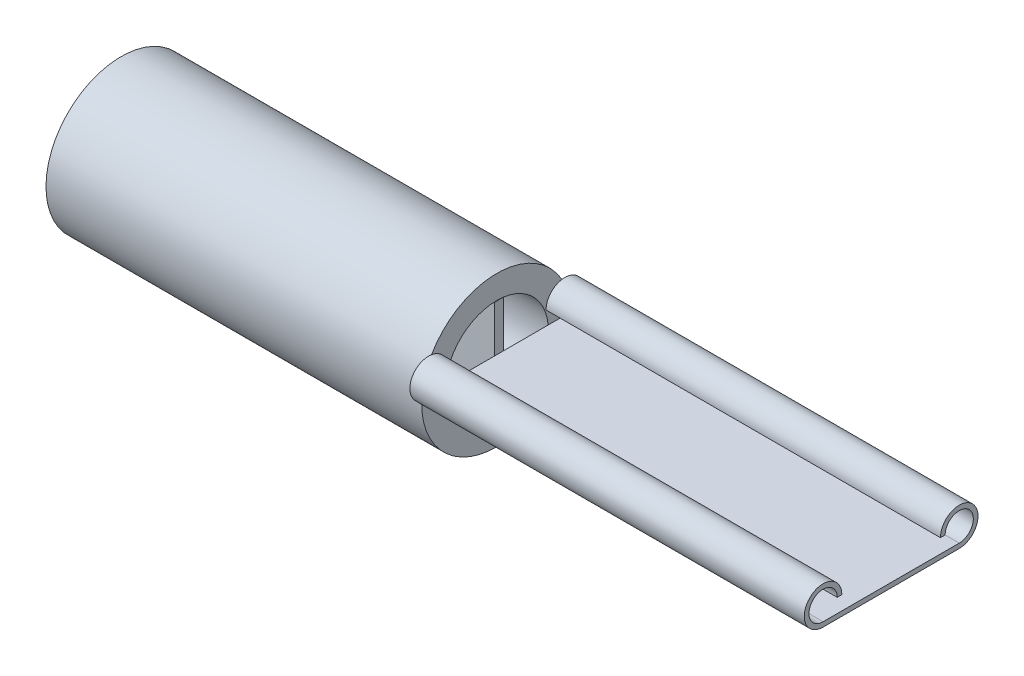
from build123d import *

# Parameters (mm, degrees)
SKETCH1_R           = 1.6
SKETCH1_R_2         = 1.1
BOSS_EXTRUDE1_DEPTH = 8
BOSS_EXTRUDE2_DEPTH = 8.4
SKETCH3_W           = 0.2
SKETCH3_H           = 2.18868951
BOSS_EXTRUDE5_DEPTH = 8


with BuildPart() as part:
    # Sketch1 → Boss-Extrude1 (new body)
    with BuildSketch(Plane(origin=(0, 0, 0), x_dir=(0, 0, -1), z_dir=(1, 0, 0))):
        Circle(SKETCH1_R)
        Circle(SKETCH1_R_2, mode=Mode.SUBTRACT)
    extrude(amount=BOSS_EXTRUDE1_DEPTH)

    # Sketch2 → Boss-Extrude2 (add)
    with BuildSketch(Plane(origin=(8, 0, 0), x_dir=(0, 0, -1), z_dir=(1, 0, 0))):
        with BuildLine():
            Line((-1.45, 0), (1.45, 0))
            ThreePointArc((1.45, 0), (1.732842712, 0.682842712), (1.05, 0.4))
            Line((1.05, 0.4), (1.15, 0.4))
            ThreePointArc((1.15, 0.4), (1.662132034, 0.612132034), (1.45, 0.1))
            Line((1.45, 0.1), (-1.45, 0.1))
            ThreePointArc((-1.45, 0.1), (-1.662132034, 0.612132034), (-1.15, 0.4))
            Line((-1.15, 0.4), (-1.05, 0.4))
            ThreePointArc((-1.05, 0.4), (-1.732842712, 0.682842712), (-1.45, 0))
        make_face()
    extrude(amount=BOSS_EXTRUDE2_DEPTH)


with BuildPart() as body_2:
    # Sketch3 → Boss-Extrude5 (new body)
    with BuildSketch(Plane.ZY):
        with Locations((-0.048883579, -0.004466927)):
            Rectangle(SKETCH3_W, SKETCH3_H)
    extrude(amount=-BOSS_EXTRUDE5_DEPTH)


solid = Compound([part.part, body_2.part])
